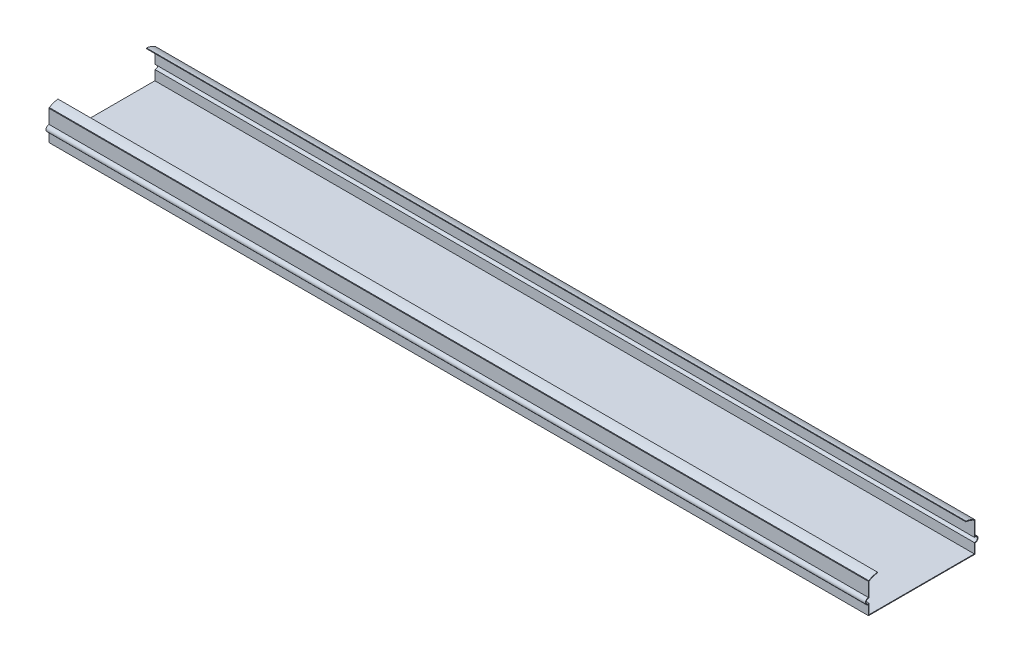
from build123d import *

# Parameters (mm, degrees)
SKETCH1_W           = 254
SKETCH1_H           = 33
BOSS_EXTRUDE1_DEPTH = 0.2
BOSS_EXTRUDE2_DEPTH = 254


with BuildPart() as part:
    # Sketch1 → Boss-Extrude1 (new body)
    with BuildSketch(Plane(origin=(0, 0, 0), x_dir=(1, 0, 0), z_dir=(0, 1, 0))):
        with Locations((-6.018162295, 0)):
            Rectangle(SKETCH1_W, SKETCH1_H)
    extrude(amount=BOSS_EXTRUDE1_DEPTH)

    # Sketch4 → Boss-Extrude2 (add)
    with BuildSketch(Plane(origin=(-133.018162295, 0, 0), x_dir=(0, 0, -1), z_dir=(1, 0, 0))):
        with BuildLine():
            Line((16.5, 0.2), (16.5, 3.005611905))
            ThreePointArc((16.5, 3.005611905), (17.439298034, 3.944909939), (16.5, 4.884207973))
            Line((16.5, 4.884207973), (16.5, 9.2))
            Line((16.5, 9.2), (16.406492637, 9.371049015))
            add(Edge.make_bspline(
                [(16.406492637, 9.371049015), (15.606591952, 9.884020198), (14.657842295, 10.216248434), (13.711270965, 10.299814324)],
                knots=[0, 0, 0, 0, 1, 1, 1, 1], degree=3))
            Line((13.711270965, 10.299814324), (13.693401418, 10.097401579))
            add(Edge.make_bspline(
                [(16.2968, 9.2), (15.089651085, 9.974136863), (13.693401418, 10.097401579)],
                knots=[0, 0, 0, 1, 1, 1], degree=2))
            Line((16.2968, 9.2), (16.2968, 4.652405576))
            ThreePointArc((16.2968, 4.652405576), (17.236098034, 3.944909939), (16.2968, 3.237414303))
            Line((16.2968, 3.237414303), (16.2968, 0.2))
            Line((16.2968, 0.2), (16.5, 0.2))
        make_face()
    boss_extrude2 = extrude(amount=BOSS_EXTRUDE2_DEPTH)

    # Mirror1: Boss-Extrude2 across plane
    add(boss_extrude2.mirror(Plane.XY))


solid = part.part
